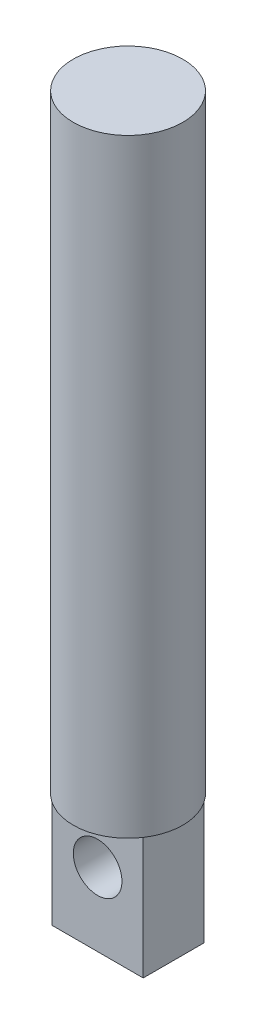
from build123d import *

# Parameters (mm, degrees)
SKETCH1_R           = 4.5
BOSS_EXTRUDE1_DEPTH = 50
SKETCH2_W           = 7.48845263
SKETCH2_H           = 4.992301796
BOSS_EXTRUDE2_DEPTH = 10
SKETCH3_R           = 2
CUT_EXTRUDE1_DEPTH  = 10


with BuildPart() as part:
    # Sketch1 → Boss-Extrude1 (new body)
    with BuildSketch(Plane(origin=(0, 0, 0), x_dir=(1, 0, 0), z_dir=(0, 1, 0))):
        Circle(SKETCH1_R)
    extrude(amount=BOSS_EXTRUDE1_DEPTH)

    # Sketch2 → Boss-Extrude2 (add)
    with BuildSketch(Plane.XZ):
        Rectangle(SKETCH2_W, SKETCH2_H)
    extrude(amount=BOSS_EXTRUDE2_DEPTH)

    # Sketch3 → Cut-Extrude1 (cut)
    with BuildSketch(Plane(origin=(0, 0, -2.496150898), x_dir=(-1, 0, 0), z_dir=(0, 0, -1))):
        with Locations((0, -4)):
            Circle(SKETCH3_R)
    extrude(amount=-CUT_EXTRUDE1_DEPTH, mode=Mode.SUBTRACT)


solid = part.part
